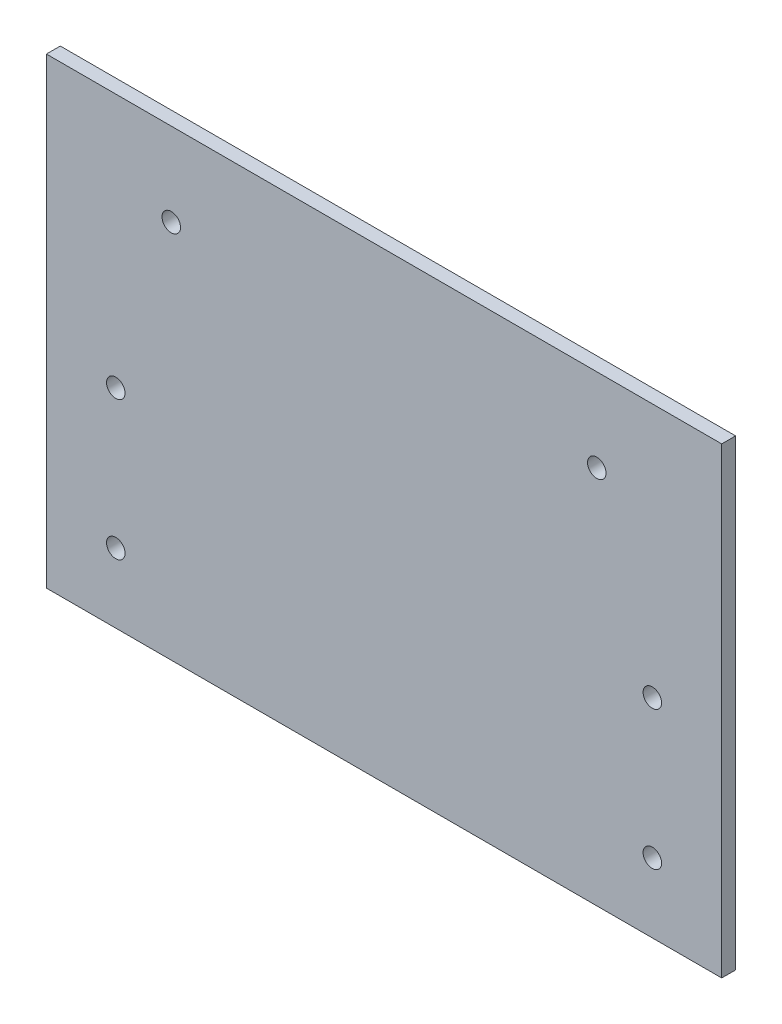
from build123d import *

# Parameters (mm, degrees)
SKETCH1_W           = 146
SKETCH1_H           = 100
BOSS_EXTRUDE1_DEPTH = 3
SKETCH2_R           = 2
CUT_EXTRUDE1_DEPTH  = 4
SKETCH3_R           = 2
CUT_EXTRUDE2_DEPTH  = 4
SKETCH4_R           = 2
CUT_EXTRUDE3_DEPTH  = 4


with BuildPart() as part:
    # Sketch1 → Boss-Extrude1 (new body)
    with BuildSketch(Plane.XY):
        with Locations((-1.123462833, 36.021174275)):
            Rectangle(SKETCH1_W, SKETCH1_H)
    extrude(amount=BOSS_EXTRUDE1_DEPTH)

    # Sketch2 → Cut-Extrude1 (cut, through all)
    with BuildSketch(Plane(origin=(0, 0, 0), x_dir=(-1, 0, 0), z_dir=(0, 0, -1))):
        with Locations((59.123462833, 1.021174275)):
            Circle(SKETCH2_R)
        with Locations((-56.876537167, 1.021174275)):
            Circle(SKETCH2_R)
    extrude(amount=-CUT_EXTRUDE1_DEPTH, mode=Mode.SUBTRACT)

    # Sketch3 → Cut-Extrude2 (cut, through all)
    with BuildSketch(Plane(origin=(0, 0, 0), x_dir=(-1, 0, 0), z_dir=(0, 0, -1))):
        with Locations((-56.876537167, 31.021174275)):
            Circle(SKETCH3_R)
        with Locations((59.123462833, 31.021174275)):
            Circle(SKETCH3_R)
    extrude(amount=-CUT_EXTRUDE2_DEPTH, mode=Mode.SUBTRACT)

    # Sketch4 → Cut-Extrude3 (cut, through all)
    with BuildSketch(Plane(origin=(0, 0, 0), x_dir=(-1, 0, 0), z_dir=(0, 0, -1))):
        with Locations((-44.866828557, 68.039856286)):
            Circle(SKETCH4_R)
        with Locations((47.124228631, 68.039856286)):
            Circle(SKETCH4_R)
    extrude(amount=-CUT_EXTRUDE3_DEPTH, mode=Mode.SUBTRACT)


solid = part.part
